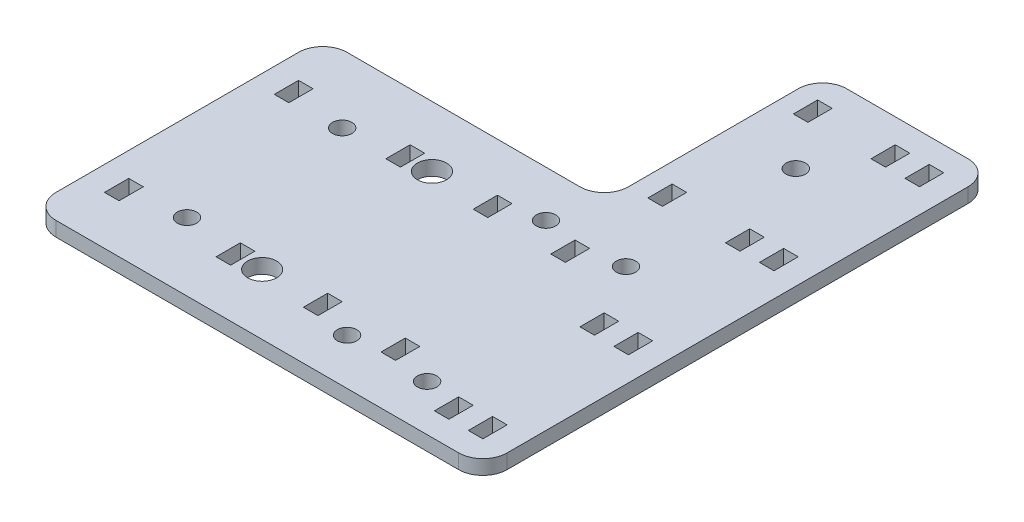
from build123d import *

# Parameters (mm, degrees)
SKETCH1_W            = 93
SKETCH1_H            = 60
BOSS_EXTRUDE1_DEPTH  = 3
SKETCH2_W            = 3
SKETCH2_H            = 5
CUT_EXTRUDE1_DEPTH   = 3
SKETCH4_W            = 35
SKETCH4_H            = 3
BOSS_EXTRUDE2_DEPTH  = 45
FILLET1_R            = 5
SKETCH5_W            = 3
SKETCH5_H            = 5
CUT_EXTRUDE3_DEPTH   = 4
LPATTERN1_COUNT      = 4
LPATTERN1_PITCH      = 30
LPATTERN1_COUNT_DIR2 = 2
LPATTERN1_PITCH_DIR2 = 30
SKETCH6_R            = 2
CUT_EXTRUDE4_DEPTH   = 4
SKETCH7_W            = 3
SKETCH7_H            = 5
CUT_EXTRUDE5_DEPTH   = 4
SKETCH8_R            = 3
CUT_EXTRUDE6_DEPTH   = 4


with BuildPart() as part:
    # Sketch1 → Boss-Extrude1 (new body)
    with BuildSketch(Plane(origin=(0, 0, 0), x_dir=(1, 0, 0), z_dir=(0, 1, 0))):
        with Locations((46.5, 30)):
            Rectangle(SKETCH1_W, SKETCH1_H)
    extrude(amount=BOSS_EXTRUDE1_DEPTH)

    # Sketch2 → Cut-Extrude1 (cut)
    with BuildSketch(Plane(origin=(0, 3, 0), x_dir=(1, 0, 0), z_dir=(0, 1, 0))):
        with Locations((63.5, 12.5)):
            Rectangle(SKETCH2_W, SKETCH2_H)
        with Locations((47.5, 12.5)):
            Rectangle(SKETCH2_W, SKETCH2_H)
        with Locations((29.5, 12.5)):
            Rectangle(SKETCH2_W, SKETCH2_H)
        with Locations((6.5, 12.5)):
            Rectangle(SKETCH2_W, SKETCH2_H)
    cut_extrude1 = extrude(amount=-CUT_EXTRUDE1_DEPTH, mode=Mode.SUBTRACT)

    # Mirror1: Cut-Extrude1 across plane
    add(cut_extrude1.mirror(Plane.XY.offset(-30)), mode=Mode.SUBTRACT)

    # Sketch4 → Boss-Extrude2 (add)
    with BuildSketch(Plane(origin=(0, 0, -60), x_dir=(-1, 0, 0), z_dir=(0, 0, -1))):
        with Locations((-75.5, 1.5)):
            Rectangle(SKETCH4_W, SKETCH4_H)
    extrude(amount=BOSS_EXTRUDE2_DEPTH)

    # Fillet1
    fillet1_edges = [part.edges().sort_by_distance(p)[0] for p in [
        (58, 1.5, -60),
        (93, 1.5, -105),
        (58, 1.5, -105),
        (0, 1.5, -60),
        (93, 1.5, 0),
        (0, 1.5, 0),
    ]]
    fillet(fillet1_edges, radius=FILLET1_R)

    # Sketch5 → Cut-Extrude3 (cut, through all)
    with BuildSketch(Plane(origin=(0, 3, 0), x_dir=(1, 0, 0), z_dir=(0, 1, 0))):
        with Locations((86.5, 7.5)):
            Rectangle(SKETCH5_W, SKETCH5_H)
        with Locations((79.5, 7.5)):
            Rectangle(SKETCH5_W, SKETCH5_H)
    cut_extrude3 = extrude(amount=-CUT_EXTRUDE3_DEPTH, mode=Mode.SUBTRACT)

    # LPattern1: Cut-Extrude3 4 × 2
    with Locations(*[(j * LPATTERN1_PITCH_DIR2, 0, -i * LPATTERN1_PITCH) for i in range(LPATTERN1_COUNT) for j in range(LPATTERN1_COUNT_DIR2) if (i, j) != (0, 0)]):
        add(cut_extrude3, mode=Mode.SUBTRACT)

    # Sketch6 → Cut-Extrude4 (cut, through all)
    with BuildSketch(Plane(origin=(0, 3, 0), x_dir=(1, 0, 0), z_dir=(0, 1, 0))):
        with Locations((18, 14)):
            Circle(SKETCH6_R)
        with Locations((18, 46)):
            Circle(SKETCH6_R)
        with Locations((55.5, 50.5)):
            Circle(SKETCH6_R)
        with Locations((55.5, 9.5)):
            Circle(SKETCH6_R)
        with Locations((72, 9.5)):
            Circle(SKETCH6_R)
        with Locations((72, 50.5)):
            Circle(SKETCH6_R)
        with Locations((72, 85.5)):
            Circle(SKETCH6_R)
    extrude(amount=-CUT_EXTRUDE4_DEPTH, mode=Mode.SUBTRACT)

    # Sketch7 → Cut-Extrude5 (cut, through all)
    with BuildSketch(Plane(origin=(0, 3, 0), x_dir=(1, 0, 0), z_dir=(0, 1, 0))):
        with Locations((63.5, 67.5)):
            Rectangle(SKETCH7_W, SKETCH7_H)
        with Locations((63.5, 97.5)):
            Rectangle(SKETCH7_W, SKETCH7_H)
    extrude(amount=-CUT_EXTRUDE5_DEPTH, mode=Mode.SUBTRACT)

    # Sketch8 → Cut-Extrude6 (cut, through all)
    with BuildSketch(Plane(origin=(0, 3, 0), x_dir=(1, 0, 0), z_dir=(0, 1, 0))):
        with Locations((35, 12.5)):
            Circle(SKETCH8_R)
        with Locations((35, 47.5)):
            Circle(SKETCH8_R)
    extrude(amount=-CUT_EXTRUDE6_DEPTH, mode=Mode.SUBTRACT)


solid = part.part
